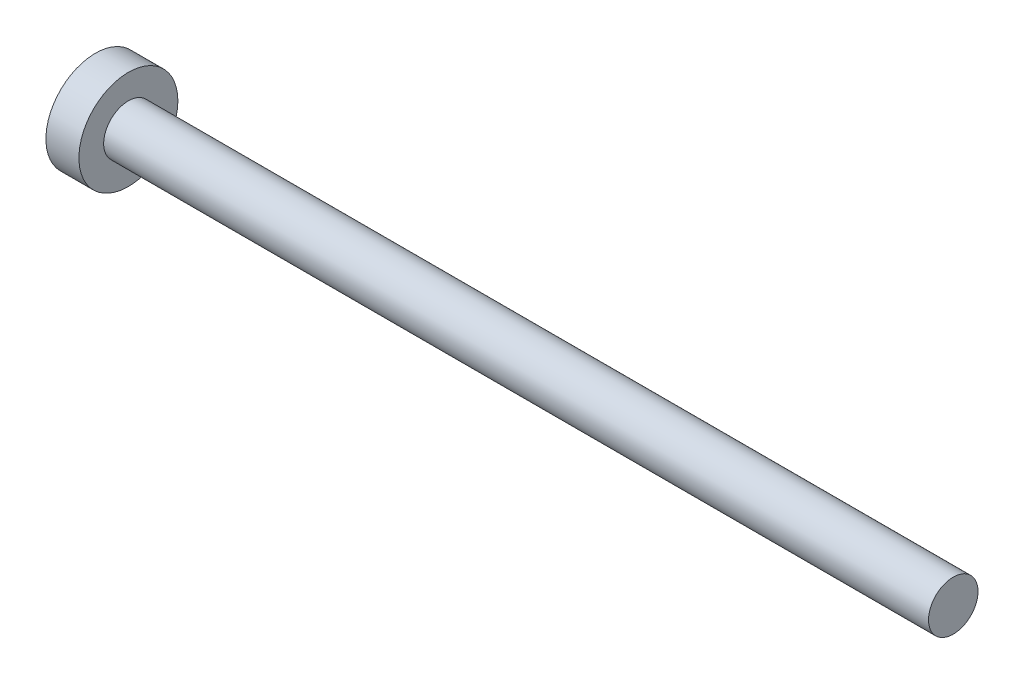
from build123d import *

# Parameters (mm, degrees)
SKETCH1_R           = 3
BOSS_EXTRUDE1_DEPTH = 2
SKETCH2_R           = 1.5
BOSS_EXTRUDE2_DEPTH = 50


with BuildPart() as part:
    # Sketch1 → Boss-Extrude1 (new body)
    with BuildSketch(Plane(origin=(0, 0, 0), x_dir=(0, 0, -1), z_dir=(1, 0, 0))):
        Circle(SKETCH1_R)
    extrude(amount=BOSS_EXTRUDE1_DEPTH)

    # Sketch2 → Boss-Extrude2 (add)
    with BuildSketch(Plane(origin=(2, 0, 0), x_dir=(0, 0, -1), z_dir=(1, 0, 0))):
        Circle(SKETCH2_R)
    extrude(amount=BOSS_EXTRUDE2_DEPTH)


solid = part.part
